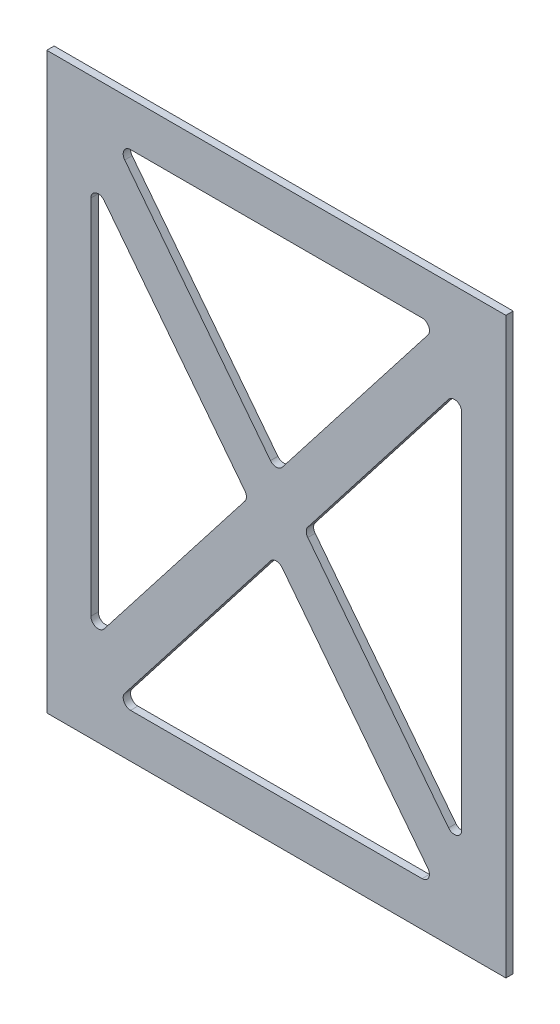
from build123d import *

# Parameters (mm, degrees)
SKETCH1_W           = 198.12
SKETCH1_H           = 247.65
BOSS_EXTRUDE1_DEPTH = 3.175
CUT_EXTRUDE1_REACH  = 5.175
FILLET1_R           = 3.175


with BuildPart() as part:
    # Sketch1 → Boss-Extrude1 (new body)
    with BuildSketch(Plane.XY):
        Rectangle(SKETCH1_W, SKETCH1_H)
    extrude(amount=BOSS_EXTRUDE1_DEPTH)

    # Sketch2 → Cut-Extrude1 (cut, up to next)
    with BuildSketch(Plane.XY.offset(3.175), mode=Mode.PRIVATE) as cut_extrude1_sk1:
        Polygon((-80.01, -87.393535256), (-12.065, 0), (-80.01, 87.393535256), align=None)
    cut_extrude1_tool1 = extrude(cut_extrude1_sk1.sketch, amount=-CUT_EXTRUDE1_REACH, mode=Mode.PRIVATE) & part.part
    add(cut_extrude1_tool1.solids().sort_by_distance((-57.361667, 0, 3.175))[0], mode=Mode.SUBTRACT)
    # Sketch2 → Cut-Extrude1 (cut, up to next)
    with BuildSketch(Plane.XY.offset(3.175), mode=Mode.PRIVATE) as cut_extrude1_sk2:
        Polygon((69.393397971, 104.775), (-69.393397971, 104.775), (0, 15.518478223), align=None)
    cut_extrude1_tool2 = extrude(cut_extrude1_sk2.sketch, amount=-CUT_EXTRUDE1_REACH, mode=Mode.PRIVATE) & part.part
    add(cut_extrude1_tool2.solids().sort_by_distance((0, 75.022826, 3.175))[0], mode=Mode.SUBTRACT)
    # Sketch2 → Cut-Extrude1 (cut, up to next)
    with BuildSketch(Plane.XY.offset(3.175), mode=Mode.PRIVATE) as cut_extrude1_sk3:
        Polygon((80.01, 87.393535256), (12.065, 0), (80.01, -87.393535256), align=None)
    cut_extrude1_tool3 = extrude(cut_extrude1_sk3.sketch, amount=-CUT_EXTRUDE1_REACH, mode=Mode.PRIVATE) & part.part
    add(cut_extrude1_tool3.solids().sort_by_distance((57.361667, 0, 3.175))[0], mode=Mode.SUBTRACT)
    # Sketch2 → Cut-Extrude1 (cut, up to next)
    with BuildSketch(Plane.XY.offset(3.175), mode=Mode.PRIVATE) as cut_extrude1_sk4:
        Polygon((69.393397971, -104.775), (0, -15.518478223), (-69.393397971, -104.775), align=None)
    cut_extrude1_tool4 = extrude(cut_extrude1_sk4.sketch, amount=-CUT_EXTRUDE1_REACH, mode=Mode.PRIVATE) & part.part
    add(cut_extrude1_tool4.solids().sort_by_distance((0, -75.022826, 3.175))[0], mode=Mode.SUBTRACT)

    # Fillet1
    fillet1_edges = [part.edges().sort_by_distance(p)[0] for p in [
        (12.065, 0, 1.5875),
        (80.01, 87.393535256, 1.5875),
        (80.01, -87.393535256, 1.5875),
        (0, 15.518478223, 1.5875),
        (-69.393397971, 104.775, 1.5875),
        (69.393397971, 104.775, 1.5875),
        (-69.393397971, -104.775, 1.5875),
        (0, -15.518478223, 1.5875),
        (69.393397971, -104.775, 1.5875),
        (-80.01, -87.393535256, 1.5875),
        (-80.01, 87.393535256, 1.5875),
        (-12.065, 0, 1.5875),
    ]]
    fillet(fillet1_edges, radius=FILLET1_R)


solid = part.part
